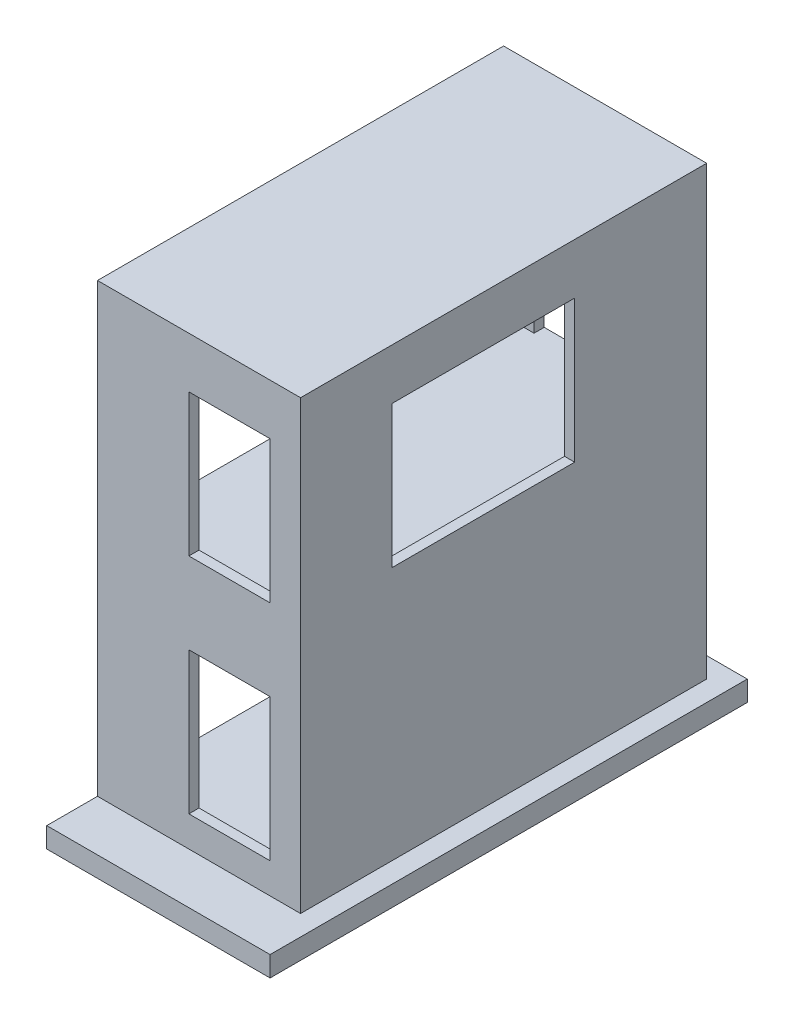
from build123d import *

# Parameters (mm, degrees)
SKETCH1_W           = 120
SKETCH1_H           = 235
FLOOR_2_DEPTH       = 10
SKETCH2_W           = 45
SKETCH2_H           = 5
BOSS_EXTRUDE2_DEPTH = 100
SKETCH3_W           = 100
SKETCH3_H           = 200
BOSS_EXTRUDE3_DEPTH = 10
SKETCH4_W           = 45
SKETCH4_H           = 5
BOSS_EXTRUDE4_DEPTH = 100
SKETCH5_W           = 100
SKETCH5_H           = 200
BOSS_EXTRUDE5_DEPTH = 10
SKETCH6_W           = 40
SKETCH6_H           = 15
BOSS_EXTRUDE6_DEPTH = 5
SKETCH7_W           = 90
SKETCH7_H           = 15
BOSS_EXTRUDE7_DEPTH = 5
SKETCH8_W           = 60
SKETCH8_H           = 80
CUT_EXTRUDE1_DEPTH  = 5
SKETCH10_W          = 10
SKETCH10_H          = 235
CUT_EXTRUDE2_DEPTH  = 10


with BuildPart() as part:
    # Sketch1 → floor 2 (new body)
    with BuildSketch(Plane(origin=(0, 0, 0), x_dir=(1, 0, 0), z_dir=(0, 1, 0))):
        Rectangle(SKETCH1_W, SKETCH1_H)
    extrude(amount=FLOOR_2_DEPTH)

    # Sketch2 → Boss-Extrude2 (add)
    with BuildSketch(Plane(origin=(0, 10, 0), x_dir=(1, 0, 0), z_dir=(0, 1, 0))):
        Polygon((-50, 102.5), (-50, 107.5), (50, 107.5), (50, -92.5), (35, -92.5), (35, -87.5), (45, -87.5), (45, 102.5), align=None)
        with Locations((-27.5, -90)):
            Rectangle(SKETCH2_W, SKETCH2_H)
    extrude(amount=BOSS_EXTRUDE2_DEPTH)

    # Sketch3 → Boss-Extrude3 (add)
    with BuildSketch(Plane(origin=(0, 110, 0), x_dir=(1, 0, 0), z_dir=(0, 1, 0))):
        with Locations((0, 7.5)):
            Rectangle(SKETCH3_W, SKETCH3_H)
    extrude(amount=BOSS_EXTRUDE3_DEPTH)

    # Sketch4 → Boss-Extrude4 (add)
    with BuildSketch(Plane(origin=(0, 120, 0), x_dir=(1, 0, 0), z_dir=(0, 1, 0))):
        Polygon((-50, 102.5), (-50, 107.5), (50, 107.5), (50, 42.5), (45, 42.5), (45, 102.5), align=None)
        with Locations((-27.5, -90)):
            Rectangle(SKETCH4_W, SKETCH4_H)
        Polygon((35, -87.5), (35, -92.5), (50, -92.5), (50, -47.5), (45, -47.5), (45, -87.5), align=None)
    extrude(amount=BOSS_EXTRUDE4_DEPTH)

    # Sketch5 → Boss-Extrude5 (add)
    with BuildSketch(Plane(origin=(0, 220, 0), x_dir=(1, 0, 0), z_dir=(0, 1, 0))):
        with Locations((0, 7.5)):
            Rectangle(SKETCH5_W, SKETCH5_H)
    extrude(amount=BOSS_EXTRUDE5_DEPTH)

    # Sketch6 → Boss-Extrude6 (add)
    with BuildSketch(Plane.XY.offset(92.5)):
        with Locations((15, 17.5)):
            Rectangle(SKETCH6_W, SKETCH6_H)
        with Locations((15, 102.5)):
            Rectangle(SKETCH6_W, SKETCH6_H)
        with Locations((15, 127.5)):
            Rectangle(SKETCH6_W, SKETCH6_H)
        with Locations((15, 212.5)):
            Rectangle(SKETCH6_W, SKETCH6_H)
    extrude(amount=-BOSS_EXTRUDE6_DEPTH)

    # Sketch7 → Boss-Extrude7 (add)
    with BuildSketch(Plane(origin=(50, 0, 0), x_dir=(0, 0, -1), z_dir=(1, 0, 0))):
        with Locations((-2.5, 127.5)):
            Rectangle(SKETCH7_W, SKETCH7_H)
        with Locations((-2.5, 212.5)):
            Rectangle(SKETCH7_W, SKETCH7_H)
    extrude(amount=-BOSS_EXTRUDE7_DEPTH)

    # Sketch8 → Cut-Extrude1 (cut)
    with BuildSketch(Plane(origin=(0, 0, -107.5), x_dir=(-1, 0, 0), z_dir=(0, 0, -1))):
        with Locations((0, 50)):
            Rectangle(SKETCH8_W, SKETCH8_H)
        with Locations((0, 160)):
            Rectangle(SKETCH8_W, SKETCH8_H)
    extrude(amount=-CUT_EXTRUDE1_DEPTH, mode=Mode.SUBTRACT)

    # Sketch10 → Cut-Extrude2 (cut)
    with BuildSketch(Plane(origin=(0, 10, 0), x_dir=(1, 0, 0), z_dir=(0, 1, 0))):
        with Locations((-55, 0)):
            Rectangle(SKETCH10_W, SKETCH10_H)
    extrude(amount=-CUT_EXTRUDE2_DEPTH, mode=Mode.SUBTRACT)


solid = part.part
